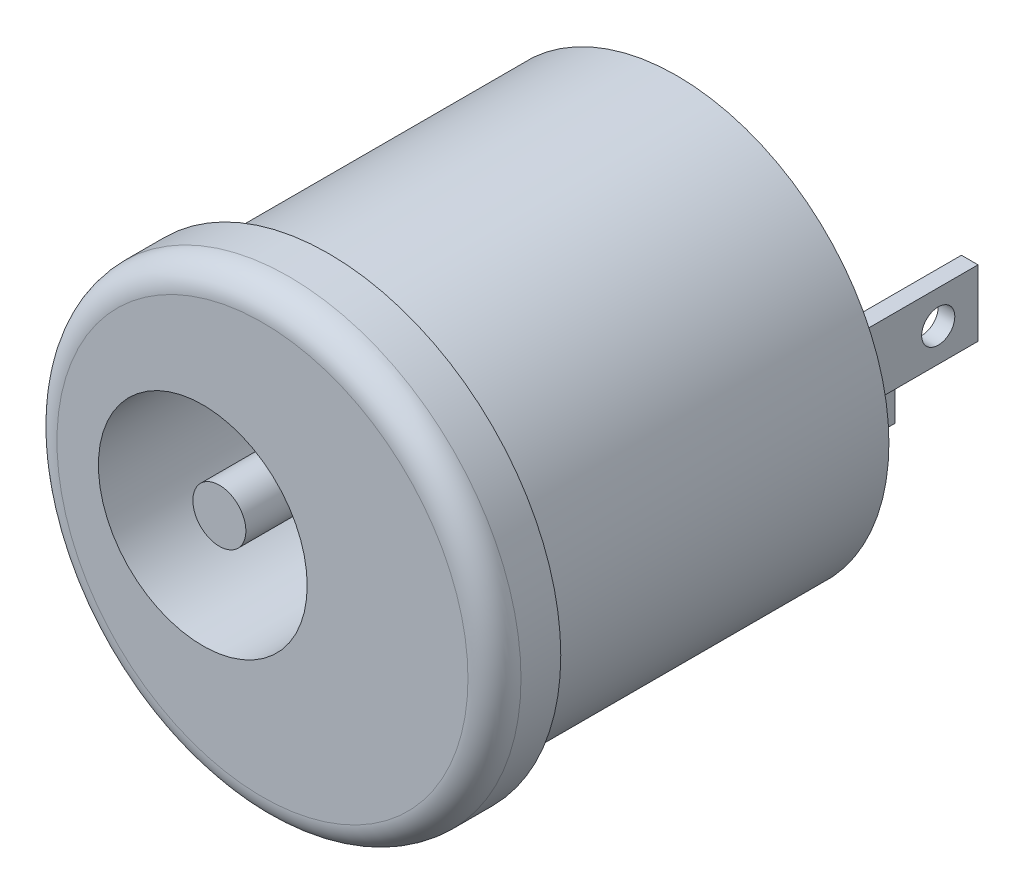
from build123d import *

# Parameters (mm, degrees)
ESQUISSE1_R             = 7
BOSS_EXTRU_1_DEPTH      = 12.5
ESQUISSE2_R             = 7
ESQUISSE2_R_2           = 6.4
ENL_V_MAT_EXTRU_1_DEPTH = 10.5
ESQUISSE4_R             = 3.15
ENL_V_MAT_EXTRU_3_DEPTH = 9
ESQUISSE5_R             = 0.8
BOSS_EXTRU_2_DEPTH      = 8.5
ESQUISSE6_W             = 0.5
ESQUISSE6_H             = 2
BOSS_EXTRU_3_DEPTH      = 5
ESQUISSE7_R             = 0.5
ENL_V_MAT_EXTRU_4_DEPTH = 9.587227572
ESQUISSE8_R             = 0.5
ENL_V_MAT_EXTRU_5_DEPTH = 12.087439586
CONG_7_R                = 0.8


with BuildPart() as part:
    # Esquisse1 → Boss.-Extru.1 (new body)
    with BuildSketch(Plane.XY):
        Circle(ESQUISSE1_R)
    extrude(amount=BOSS_EXTRU_1_DEPTH)

    # Esquisse2 → Enlèv. mat.-Extru.1 (cut)
    with BuildSketch(Plane(origin=(0, 0, 0), x_dir=(-1, 0, 0), z_dir=(0, 0, -1))):
        Circle(ESQUISSE2_R)
        Circle(ESQUISSE2_R_2, mode=Mode.SUBTRACT)
    extrude(amount=-ENL_V_MAT_EXTRU_1_DEPTH, mode=Mode.SUBTRACT)

    # Esquisse4 → Enlèv. mat.-Extru.3 (cut)
    with BuildSketch(Plane.XY.offset(12.5)):
        with Locations((-1.8, 0)):
            Circle(ESQUISSE4_R)
    extrude(amount=-ENL_V_MAT_EXTRU_3_DEPTH, mode=Mode.SUBTRACT)

    # Esquisse5 → Boss.-Extru.2 (add)
    with BuildSketch(Plane.XY.offset(3.5)):
        with Locations((-1.8, 0)):
            Circle(ESQUISSE5_R)
    extrude(amount=BOSS_EXTRU_2_DEPTH)

    # Esquisse6 → Boss.-Extru.3 (add)
    with BuildSketch(Plane(origin=(0, 0, 0), x_dir=(-1, 0, 0), z_dir=(0, 0, -1))):
        with Locations((-3.837439586, 0)):
            Rectangle(ESQUISSE6_W, ESQUISSE6_H)
        with Locations((-1.337227572, -3.389935619)):
            Rectangle(ESQUISSE6_W, ESQUISSE6_H)
    extrude(amount=BOSS_EXTRU_3_DEPTH)

    # Esquisse7 → Enlèv. mat.-Extru.4 (cut, through all)
    with BuildSketch(Plane(origin=(1.587227572, 0, 0), x_dir=(0, 0, -1), z_dir=(1, 0, 0))):
        with Locations((3.8, -3.389935619)):
            Circle(ESQUISSE7_R)
    extrude(amount=-ENL_V_MAT_EXTRU_4_DEPTH, mode=Mode.SUBTRACT)

    # Esquisse8 → Enlèv. mat.-Extru.5 (cut, through all)
    with BuildSketch(Plane(origin=(4.087439586, 0, 0), x_dir=(0, 0, -1), z_dir=(1, 0, 0))):
        with Locations((3.8, 0)):
            Circle(ESQUISSE8_R)
    extrude(amount=-ENL_V_MAT_EXTRU_5_DEPTH, mode=Mode.SUBTRACT)

    # Congé7
    cong_7_edges = [part.edges().sort_by_distance(p)[0] for p in [
        (-7, 0, 12.5),
    ]]
    fillet(cong_7_edges, radius=CONG_7_R)


solid = part.part
